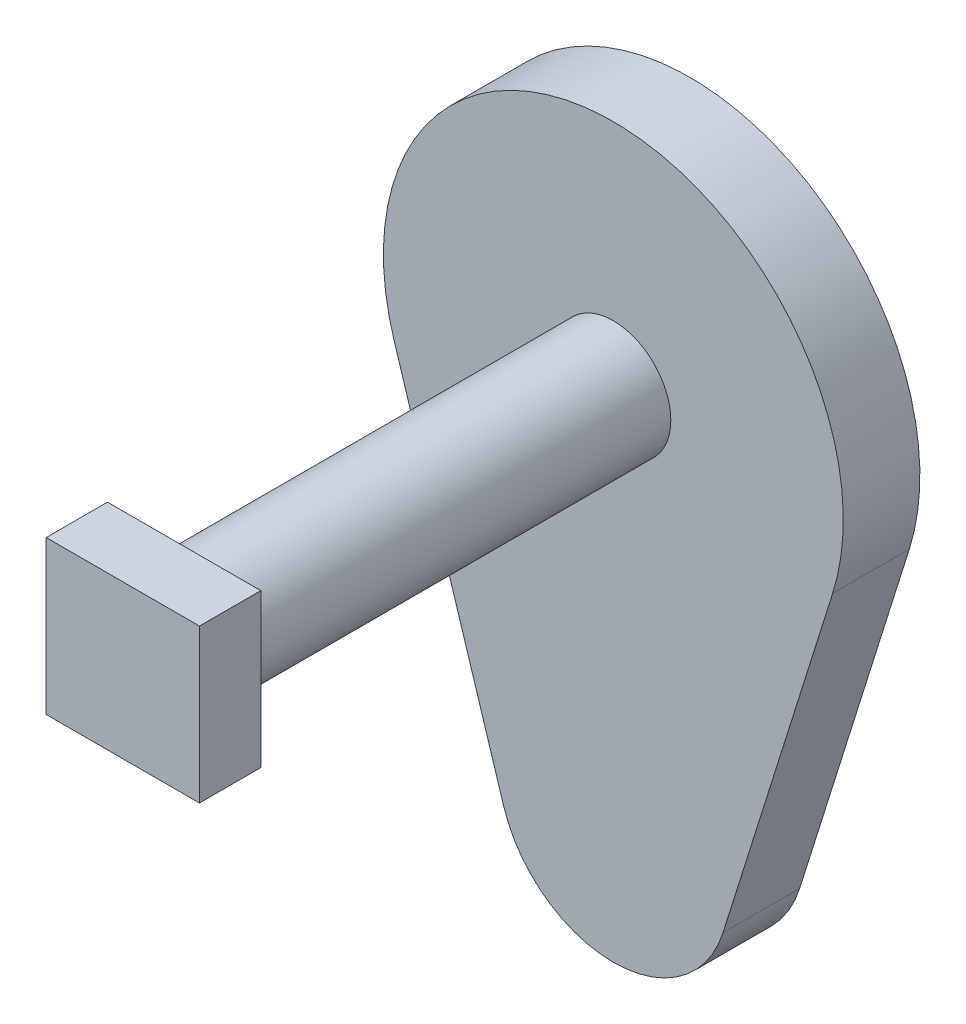
from build123d import *

# Parameters (mm, degrees)
BOSS_EXTRUDE1_DEPTH = 10
SKETCH2_R           = 7.5
BOSS_EXTRUDE2_DEPTH = 56
SKETCH3_W           = 20
SKETCH3_H           = 20
BOSS_EXTRUDE3_DEPTH = 8


with BuildPart() as part:
    # Sketch1 → Boss-Extrude1 (new body)
    with BuildSketch(Plane.XY):
        with BuildLine():
            Line((-28.618176043, 41), (-14.309088021, -4.5))
            ThreePointArc((-14.309088021, -4.5), (0, -15), (14.309088021, -4.5))
            Line((14.309088021, -4.5), (28.618176042, 41))
            ThreePointArc((28.618176042, 41), (0, 80), (-28.618176043, 41))
        make_face()
    extrude(amount=BOSS_EXTRUDE1_DEPTH)

    # Sketch2 → Boss-Extrude2 (add)
    with BuildSketch(Plane.XY.offset(10)):
        with Locations((0, 50)):
            Circle(SKETCH2_R)
    extrude(amount=BOSS_EXTRUDE2_DEPTH)

    # Sketch3 → Boss-Extrude3 (add)
    with BuildSketch(Plane.XY.offset(66)):
        with Locations((0, 50)):
            Rectangle(SKETCH3_W, SKETCH3_H)
    extrude(amount=BOSS_EXTRUDE3_DEPTH)


solid = part.part
